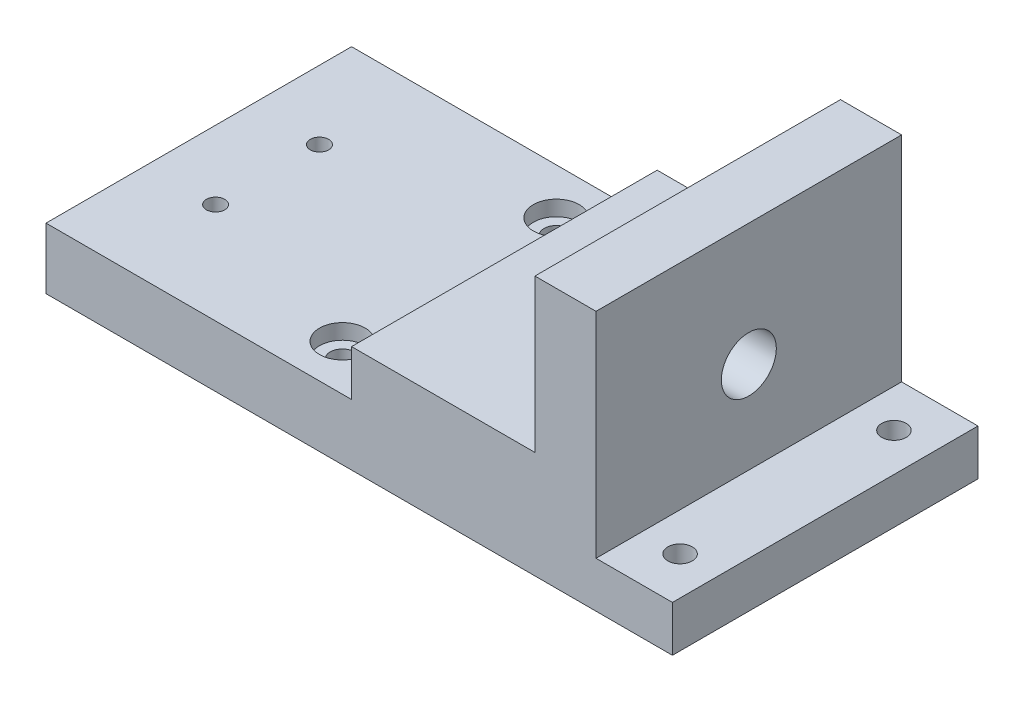
from build123d import *

# Parameters (mm, degrees)
BOSS_EXTRUDE1_DEPTH = 50
SKETCH3_R           = 9
CUT_EXTRUDE1_DEPTH  = 50
SKETCH4_W           = 60
SKETCH4_H           = 42
BOSS_EXTRUDE3_DEPTH = 15
SKETCH6_R           = 3
SKETCH6_R_2         = 4
CUT_EXTRUDE3_DEPTH  = 21
SKETCH6_4_R         = 7.5
CUT_EXTRUDE4_DEPTH  = 5


with BuildPart() as part:
    # Sketch2 → Boss-Extrude1 (new body, symmetric)
    with BuildSketch(Plane.XY):
        Polygon((0, 0), (0, 15), (-25, 15), (-25, 85), (-45, 85), (-45, 35), (-105, 35), (-105, 20), (-205, 20), (-205, 0), align=None)
    extrude(amount=BOSS_EXTRUDE1_DEPTH, both=True)

    # Sketch3 → Cut-Extrude1 (cut, symmetric)
    with BuildSketch(Plane(origin=(-25, 0, 0), x_dir=(0, 0, -1), z_dir=(1, 0, 0))):
        with Locations((0, 45)):
            Circle(SKETCH3_R)
    extrude(amount=CUT_EXTRUDE1_DEPTH, both=True, mode=Mode.SUBTRACT)

    # Sketch4 → Boss-Extrude3 (add)
    with BuildSketch(Plane(origin=(0, 35, 0), x_dir=(1, 0, 0), z_dir=(0, 1, 0))):
        with Locations((-75, 0)):
            Rectangle(SKETCH4_W, SKETCH4_H)
    extrude(amount=-BOSS_EXTRUDE3_DEPTH)

    # Sketch6 → Cut-Extrude3 (cut, through all)
    with BuildSketch(Plane(origin=(0, 20, 0), x_dir=(1, 0, 0), z_dir=(0, 1, 0))):
        with Locations((-182.5, 17)):
            Circle(SKETCH6_R)
        with Locations((-123, 35)):
            Circle(SKETCH6_R_2)
        with Locations((-12.5, 35)):
            Circle(SKETCH6_R_2)
        with Locations((-12.5, -35)):
            Circle(SKETCH6_R_2)
        with Locations((-123, -35)):
            Circle(SKETCH6_R_2)
        with Locations((-182.5, -17)):
            Circle(SKETCH6_R)
    extrude(amount=-CUT_EXTRUDE3_DEPTH, mode=Mode.SUBTRACT)

    # Sketch6_4 → Cut-Extrude4 (cut)
    with BuildSketch(Plane(origin=(0, 20, 0), x_dir=(1, 0, 0), z_dir=(0, 1, 0))):
        with Locations((-123, 35)):
            Circle(SKETCH6_4_R)
        with Locations((-12.5, 35)):
            Circle(SKETCH6_4_R)
        with Locations((-12.5, -35)):
            Circle(SKETCH6_4_R)
        with Locations((-123, -35)):
            Circle(SKETCH6_4_R)
    extrude(amount=-CUT_EXTRUDE4_DEPTH, mode=Mode.SUBTRACT)


solid = part.part
